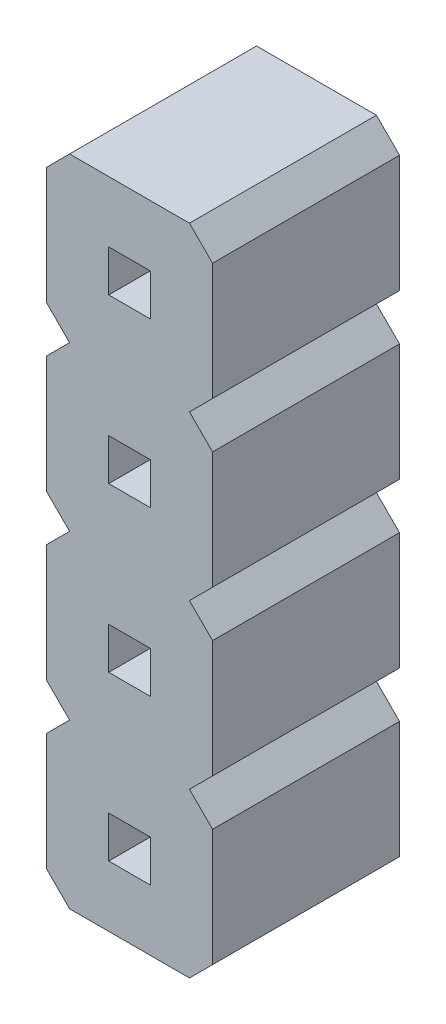
from build123d import *

# Parameters (mm, degrees)
PIN_DRAWING_W       = 0.636
PIN_DRAWING_H       = 0.636
BOSS_EXTRUDE1_DEPTH = 2.86


with BuildPart() as part:
    # pin_drawing → Boss-Extrude1 (new body)
    with BuildSketch(Plane.XY):
        Polygon((0, 2.146446609), (0, 0.353553391), (0.353553391, 0), (0, -0.353553391), (0, -2.146446609), (0.353553391, -2.5), (2.187446609, -2.5), (2.541, -2.146446609), (2.541, -0.353553391), (2.187446609, 0), (2.541, 0.353553391), (2.541, 2.146446609), (2.187446609, 2.5), (2.541, 2.853553391), (2.541, 4.646446609), (2.187446609, 5), (2.541, 5.353553391), (2.541, 7.146446609), (2.187446609, 7.5), (0.353553391, 7.5), (0, 7.146446609), (0, 5.353553391), (0.353553391, 5), (0, 4.646446609), (0, 2.853553391), (0.353553391, 2.5), align=None)
        with Locations((1.2705, -1.25)):
            Rectangle(PIN_DRAWING_W, PIN_DRAWING_H, mode=Mode.SUBTRACT)
        with Locations((1.2705, 1.25)):
            Rectangle(PIN_DRAWING_W, PIN_DRAWING_H, mode=Mode.SUBTRACT)
        with Locations((1.2705, 3.75)):
            Rectangle(PIN_DRAWING_W, PIN_DRAWING_H, mode=Mode.SUBTRACT)
        with Locations((1.2705, 6.25)):
            Rectangle(PIN_DRAWING_W, PIN_DRAWING_H, mode=Mode.SUBTRACT)
    extrude(amount=BOSS_EXTRUDE1_DEPTH)


solid = part.part
